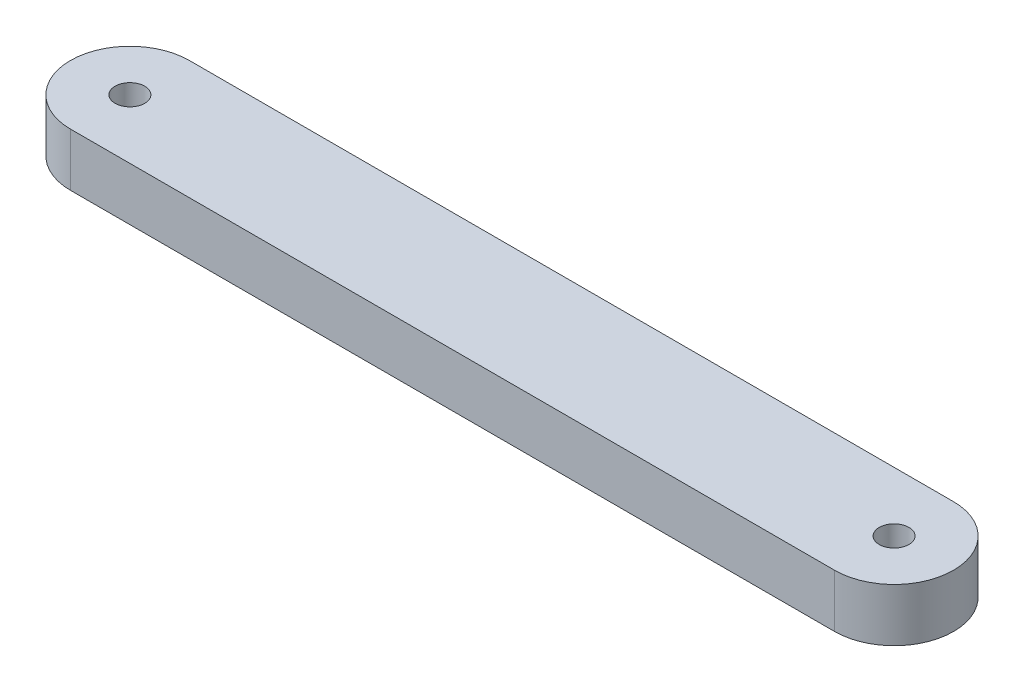
from build123d import *

# Parameters (mm, degrees)
SKETCH_1_R      = 28
SKETCH_1_R_2    = 7
EXTRUDE_1_DEPTH = 25


with BuildPart() as part:
    # 草图1 → 凸台-拉伸1 (new body)
    with BuildSketch(Plane(origin=(0, 0, 0), x_dir=(1, 0, 0), z_dir=(0, 1, 0))):
        with BuildLine():
            Line((180, 28), (-180, 28))
            ThreePointArc((-180, 28), (-160.201010127, 19.798989873), (-152, 0))
            ThreePointArc((-152, 0), (-160.201010127, -19.798989873), (-180, -28))
            Line((-180, -28), (180, -28))
            ThreePointArc((180, -28), (152, 0), (180, 28))
        make_face()
        with Locations((180, 0)):
            Circle(SKETCH_1_R)
        with Locations((180, 0)):
            Circle(SKETCH_1_R_2, mode=Mode.SUBTRACT)
        with Locations((-180, 0)):
            Circle(SKETCH_1_R)
        with Locations((-180, 0)):
            Circle(SKETCH_1_R_2, mode=Mode.SUBTRACT)
    extrude(amount=EXTRUDE_1_DEPTH)


solid = part.part
